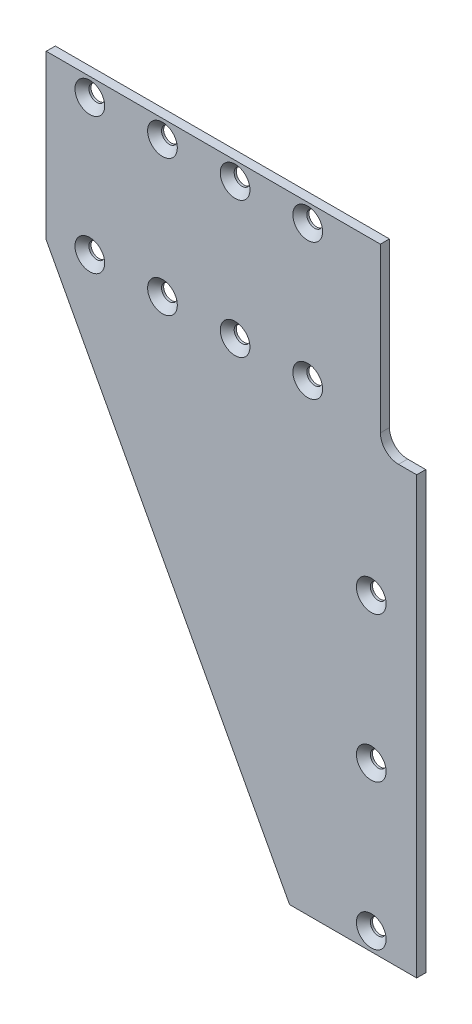
from build123d import *

# Parameters (mm, degrees)
BOSS_EXTRUDE1_DEPTH                       = 3.175
CSK_FOR_0_FLAT_HEAD_MACHINE_SCREW_2_COUNT = 2
CSK_FOR_0_FLAT_HEAD_MACHINE_SCREW_2_PITCH = 47.625
LPATTERN1_COUNT                           = 4
LPATTERN1_PITCH                           = 25.4
LPATTERN2_COUNT                           = 3
LPATTERN2_PITCH                           = 50.8


with BuildPart() as part:
    # Sketch1 → Boss-Extrude1 (new body)
    with BuildSketch(Plane.XY):
        with BuildLine():
            Line((0, 0), (0, 152.4))
            Line((0, 152.4), (-6.35, 152.4))
            ThreePointArc((-6.35, 152.4), (-10.840128061, 154.259871939), (-12.7, 158.75))
            Line((-12.7, 158.75), (-12.7, 215.9))
            Line((-12.7, 215.9), (-129.54, 215.9))
            Line((-129.54, 215.9), (-129.54, 158.75))
            Line((-129.54, 158.75), (-44.45, 0))
            Line((-44.45, 0), (0, 0))
        make_face()
    extrude(amount=-BOSS_EXTRUDE1_DEPTH)

    # Sketch3 → CSK for _0 Flat Head Machine Screw _100 (revolve, cut)
    with BuildSketch(Plane(origin=(-114.3, 209.55, 0), x_dir=(0, -1, 0), z_dir=(1, 0, 0))):
        Polygon((0, 0), (0, 3.175), (2.7559, 3.175), (2.7559, 2.4384), (5.1943, 0), align=None)
    csk_for_0_flat_head_machine_screw_100 = revolve(axis=Axis((-114.3, 209.55, 6.35), (0, 0, -1)), mode=Mode.SUBTRACT)

    # CSK for _0 Flat Head Machine Screw _ 2: CSK for _0 Flat Head Machine Screw _100 ×2
    with Locations(*[(0, -i * CSK_FOR_0_FLAT_HEAD_MACHINE_SCREW_2_PITCH, 0) for i in range(1, CSK_FOR_0_FLAT_HEAD_MACHINE_SCREW_2_COUNT)]):
        add(csk_for_0_flat_head_machine_screw_100, mode=Mode.SUBTRACT)

    # LPattern1: CSK for _0 Flat Head Machine Screw _100 ×4
    with Locations(*[(i * LPATTERN1_PITCH, 0, 0) for i in range(1, LPATTERN1_COUNT)]):
        add(csk_for_0_flat_head_machine_screw_100, mode=Mode.SUBTRACT)

    # LPattern1 copy 1 sketch → LPattern1 copy 1 (revolve, cut)
    with BuildSketch(Plane(origin=(-88.9, 161.925, 0), x_dir=(0, -1, 0), z_dir=(1, 0, 0))):
        Polygon((0, 0), (0, 3.175), (2.7559, 3.175), (2.7559, 2.4384), (5.1943, 0), align=None)
    revolve(axis=Axis((-88.9, 161.925, 6.35), (0, 0, -1)), mode=Mode.SUBTRACT)

    # LPattern1 copy 2 sketch → LPattern1 copy 2 (revolve, cut)
    with BuildSketch(Plane(origin=(-63.5, 161.925, 0), x_dir=(0, -1, 0), z_dir=(1, 0, 0))):
        Polygon((0, 0), (0, 3.175), (2.7559, 3.175), (2.7559, 2.4384), (5.1943, 0), align=None)
    revolve(axis=Axis((-63.5, 161.925, 6.35), (0, 0, -1)), mode=Mode.SUBTRACT)

    # LPattern1 copy 3 sketch → LPattern1 copy 3 (revolve, cut)
    with BuildSketch(Plane(origin=(-38.1, 161.925, 0), x_dir=(0, -1, 0), z_dir=(1, 0, 0))):
        Polygon((0, 0), (0, 3.175), (2.7559, 3.175), (2.7559, 2.4384), (5.1943, 0), align=None)
    revolve(axis=Axis((-38.1, 161.925, 6.35), (0, 0, -1)), mode=Mode.SUBTRACT)

    # Sketch4 → CSK for _0 Flat Head Machine Screw _ 3 (revolve, cut)
    with BuildSketch(Plane(origin=(-15.875, 107.95, 0), x_dir=(0, -1, 0), z_dir=(1, 0, 0))):
        Polygon((0, 0), (0, 3.175), (2.7559, 3.175), (2.7559, 2.4384), (5.1943, 0), align=None)
    csk_for_0_flat_head_machine_screw_3 = revolve(axis=Axis((-15.875, 107.95, 6.35), (0, 0, -1)), mode=Mode.SUBTRACT)

    # LPattern2: CSK for _0 Flat Head Machine Screw _ 3 ×3
    with Locations(*[(0, -i * LPATTERN2_PITCH, 0) for i in range(1, LPATTERN2_COUNT)]):
        add(csk_for_0_flat_head_machine_screw_3, mode=Mode.SUBTRACT)


solid = part.part
